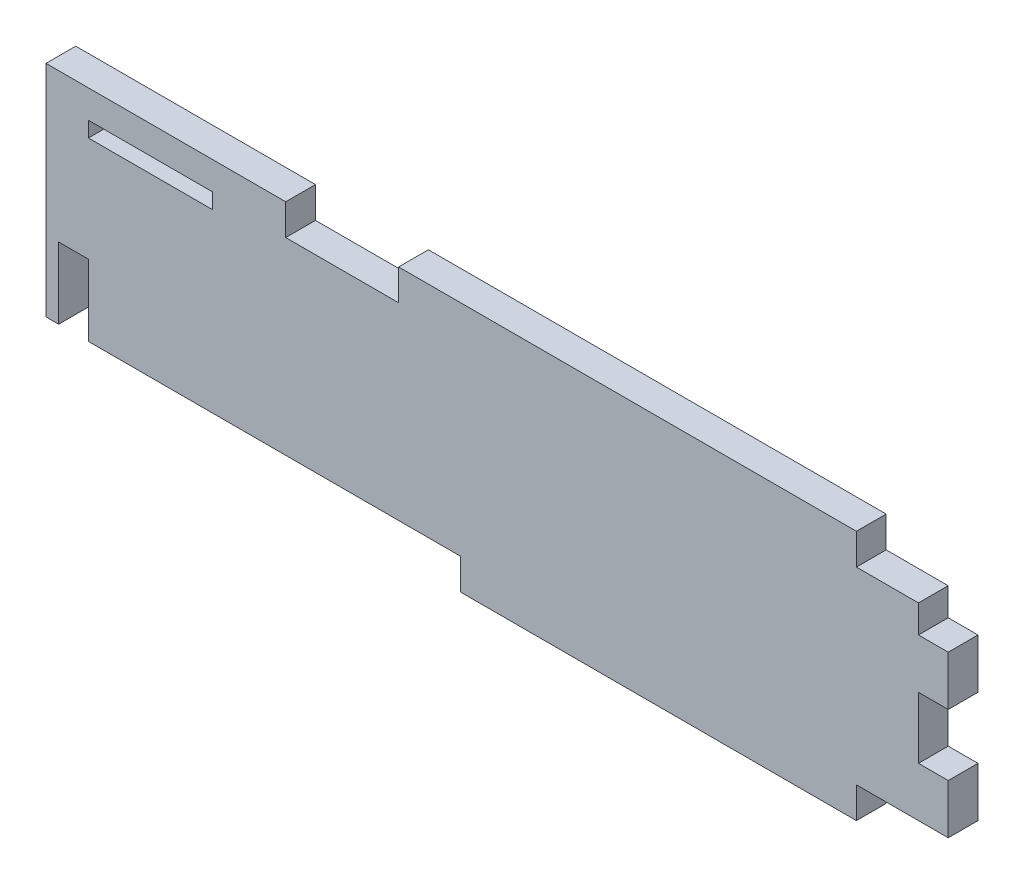
from build123d import *

# Parameters (mm, degrees)
SKETCH1_W           = 12.7
SKETCH1_H           = 1.5748
BOSS_EXTRUDE1_DEPTH = 3.048
SKETCH2_W           = 12.7
SKETCH2_H           = 0.1016
BOSS_EXTRUDE2_DEPTH = 3.048
SKETCH3_W           = 3.048
SKETCH3_H           = 7.2898
CUT_EXTRUDE1_DEPTH  = 4.048


with BuildPart() as part:
    # Sketch1 → Boss-Extrude1 (new body)
    with BuildSketch(Plane.XY):
        Polygon((-6.35, 1.5494), (-6.35, 4.7244), (3.048, 4.7244), (3.048, 9.8044), (0, 9.8044), (0, 16.1036), (3.048, 16.1036), (3.048, 21.1836), (0, 21.1836), (0, 24.0284), (-6.35, 24.0284), (-6.35, 27.2034), (-53.213, 27.2034), (-53.213, 24.0284), (-64.77, 24.0284), (-64.77, 27.2034), (-89.3064, 27.2034), (-89.3064, 15.9639), (-89.3064, 4.7244), (-86.7664, 4.7244), (-86.7664, 12.0142), (-84.963, 12.0142), (-84.963, 4.7244), (-46.863, 4.7244), (-46.863, 1.5494), align=None)
        with Locations((-78.613, 23.5458)):
            Rectangle(SKETCH1_W, SKETCH1_H, mode=Mode.SUBTRACT)
    extrude(amount=BOSS_EXTRUDE1_DEPTH)

    # Sketch2 → Boss-Extrude2 (add)
    with BuildSketch(Plane.XY.offset(3.048)):
        with Locations((-78.613, 24.384)):
            Rectangle(SKETCH2_W, SKETCH2_H)
    extrude(amount=-BOSS_EXTRUDE2_DEPTH)

    # Sketch3 → Cut-Extrude1 (cut, through all)
    with BuildSketch(Plane.XY.offset(3.048)):
        with Locations((-86.487, 8.3693)):
            Rectangle(SKETCH3_W, SKETCH3_H)
    extrude(amount=-CUT_EXTRUDE1_DEPTH, mode=Mode.SUBTRACT)


solid = part.part
